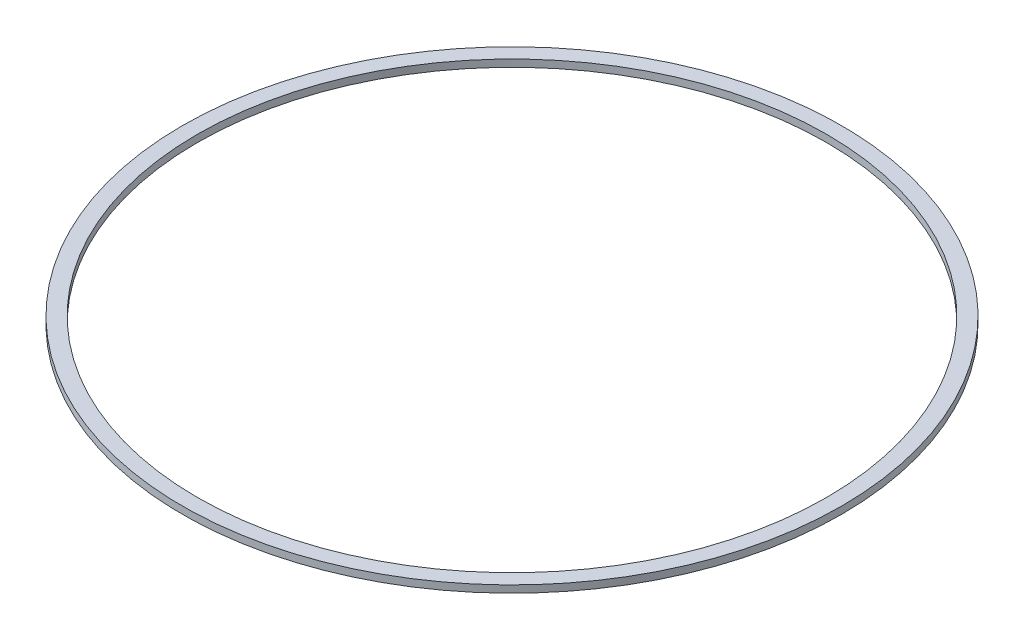
from build123d import *

# Parameters (mm, degrees)
SKETCH3_W = 2.5
SKETCH3_H = 1.2


with BuildPart() as part:
    # Sketch3 → Revolve1 (revolve)
    with BuildSketch(Plane.XY):
        with Locations((-53.75, 8.7)):
            Rectangle(SKETCH3_W, SKETCH3_H)
    revolve(axis=Axis((0, 0, 0), (0, 1, 0)))


solid = part.part
